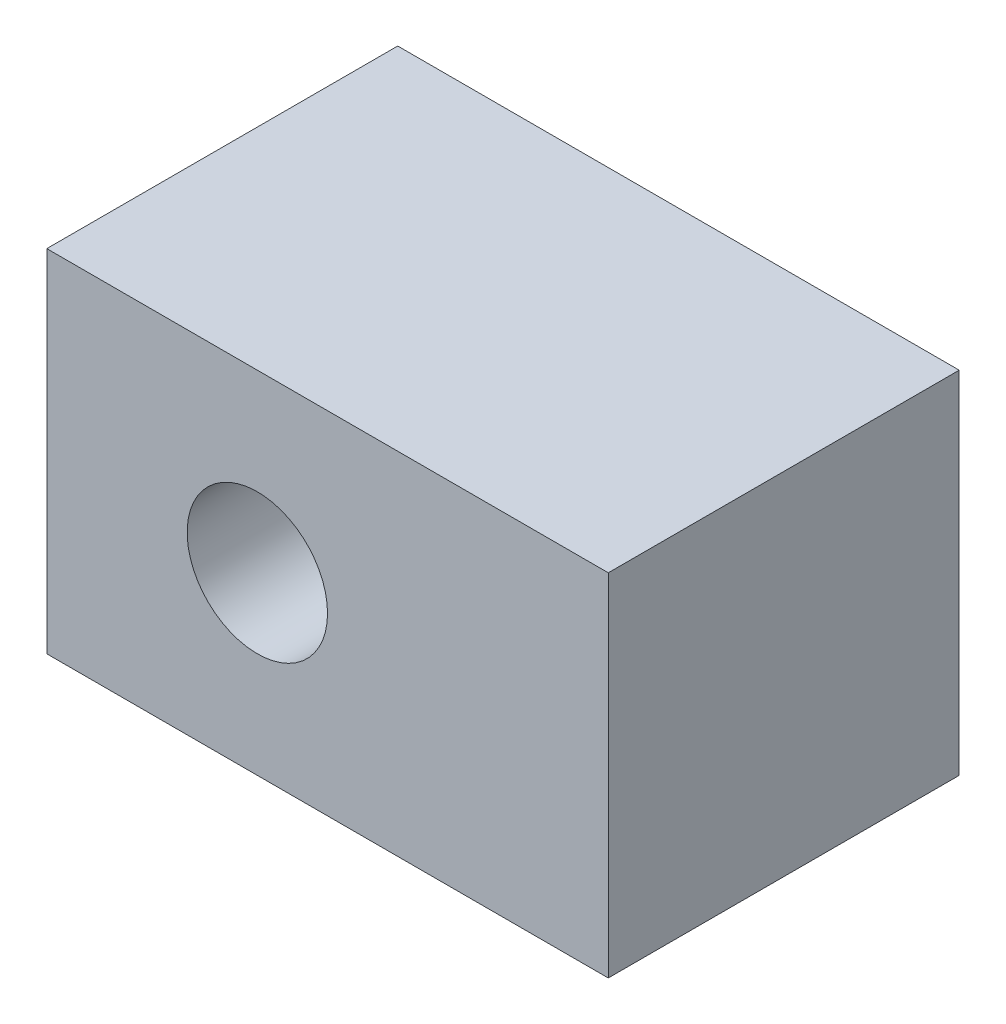
from build123d import *

# Parameters (mm, degrees)
SKETCH_1_W      = 80
SKETCH_1_H      = 50
SKETCH_1_R      = 10
EXTRUDE_1_DEPTH = 25


with BuildPart() as part:
    # Эскиз1 → Бобышка-Вытянуть1 (new body, symmetric)
    with BuildSketch(Plane.XY):
        with Locations((10, 0)):
            Rectangle(SKETCH_1_W, SKETCH_1_H)
        Circle(SKETCH_1_R, mode=Mode.SUBTRACT)
    extrude(amount=EXTRUDE_1_DEPTH, both=True)


solid = part.part
